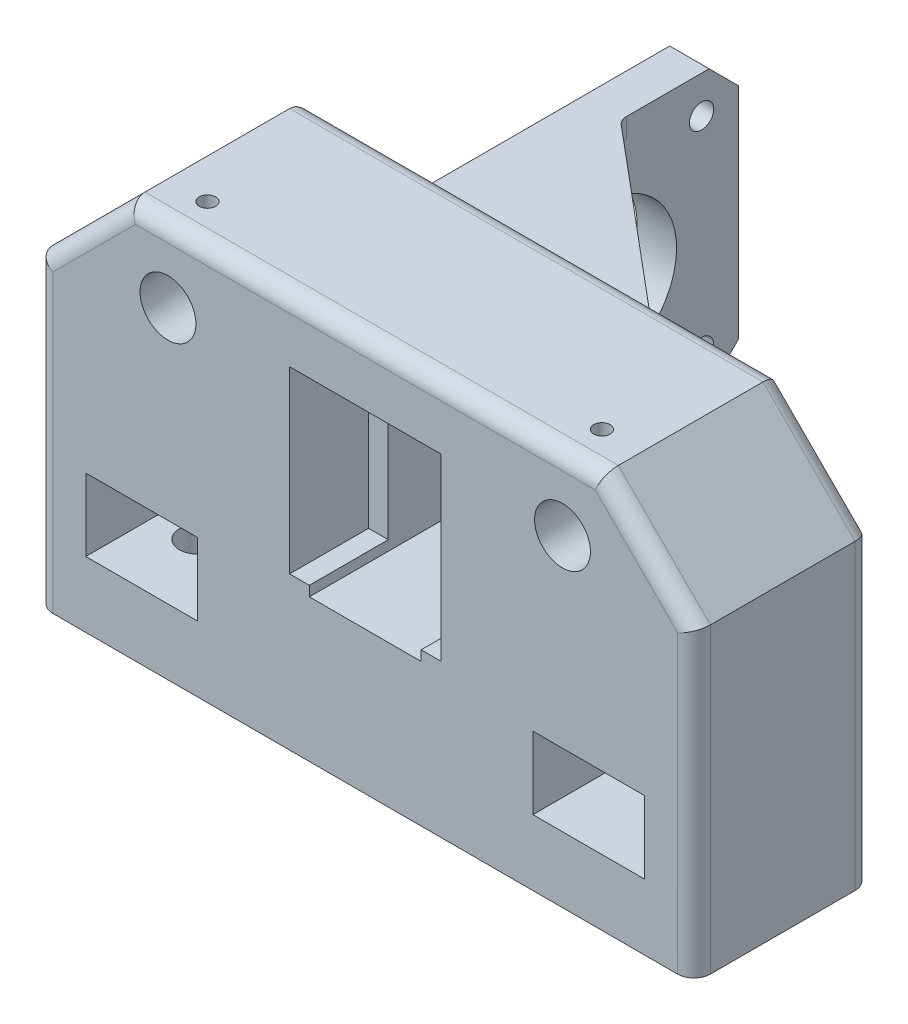
from build123d import *

# Parameters (mm, degrees)
SKETCH1_W            = 100
SKETCH1_H            = 60
SKETCH1_R            = 4.25
BOSS_EXTRUDE1_DEPTH  = 13.5
SKETCH2_R            = 7
BOSS_EXTRUDE2_DEPTH  = 10
CHAMFER1_SIZE        = 14
FILLET1_R            = 2.5
CUT_EXTRUDE1_DEPTH   = 12
SKETCH5_R            = 1.25
CUT_EXTRUDE2_DEPTH   = 12
SKETCH6_R            = 2.75
CUT_EXTRUDE3_DEPTH   = 10
CUT_EXTRUDE4_DEPTH   = 17
SKETCH11_W           = 17
SKETCH11_H           = 28.01
CUT_EXTRUDE5_DEPTH   = 28.0000001
SKETCH13_R           = 4.25
BOSS_EXTRUDE6_DEPTH  = 9
SKETCH14_R           = 1.85
SKETCH14_R_2         = 11.7
BOSS_EXTRUDE7_DEPTH  = 6
BOSS_EXTRUDE8_START  = 4
BOSS_EXTRUDE8_DEPTH  = 3
SKETCH17_W           = 6
SKETCH17_H           = 42.718705864
BOSS_EXTRUDE9_DEPTH  = 1
BOSS_EXTRUDE12_DEPTH = 3
SKETCH19_W           = 6
SKETCH19_H           = 24.5
BOSS_EXTRUDE13_DEPTH = 6
SKETCH21_W           = 6
SKETCH21_H           = 21.281155669
BOSS_EXTRUDE14_DEPTH = 3
BOSS_EXTRUDE15_DEPTH = 3
FILLET3_R            = 2


with BuildPart() as part:
    # Sketch1 → Boss-Extrude1 (new body, symmetric)
    with BuildSketch(Plane.XY):
        with Locations((0, -19)):
            Rectangle(SKETCH1_W, SKETCH1_H)
        with Locations((30, 0)):
            Circle(SKETCH1_R, mode=Mode.SUBTRACT)
        with Locations((-30, 0)):
            Circle(SKETCH1_R, mode=Mode.SUBTRACT)
    extrude(amount=BOSS_EXTRUDE1_DEPTH, both=True)

    # Sketch2 → Boss-Extrude2 (add)
    with BuildSketch(Plane(origin=(0, 0, -13.5), x_dir=(-1, 0, 0), z_dir=(0, 0, -1))):
        with Locations((-30, 0)):
            Circle(SKETCH2_R)
        with Locations((30, 0)):
            Circle(SKETCH2_R)
    extrude(amount=-BOSS_EXTRUDE2_DEPTH)

    # Chamfer1
    chamfer1_edges = [part.edges().sort_by_distance(p)[0] for p in [
        (-50, 11, 0),
        (50, 11, 0),
    ]]
    chamfer(chamfer1_edges, length=CHAMFER1_SIZE)

    # Fillet1
    fillet1_edges = [part.edges().sort_by_distance(p)[0] for p in [
        (-50, -26, -13.5),
        (-50, -26, 13.5),
        (0, 11, -13.5),
        (43, 4, -13.5),
        (-43, 4, -13.5),
        (0, 11, 13.5),
        (50, -26, 13.5),
        (43, 4, 13.5),
        (-43, 4, 13.5),
        (50, -26, -13.5),
    ]]
    fillet(fillet1_edges, radius=FILLET1_R)

    # Sketch3 → Cut-Extrude1 (cut)
    with BuildSketch(Plane.XY.offset(13.5)):
        Polygon((11.5, 1.5), (-11.5, 1.5), (-11.5, -14.75), (-11.5, -25.79), (11.5, -25.79), (11.5, -14.75), align=None)
    extrude(amount=-CUT_EXTRUDE1_DEPTH, mode=Mode.SUBTRACT)

    # Sketch5 → Cut-Extrude2 (cut)
    with BuildSketch(Plane(origin=(0, 11, 0), x_dir=(1, 0, 0), z_dir=(0, 1, 0))):
        with Locations((30, -7.5)):
            Circle(SKETCH5_R)
        with Locations((-30, -7.5)):
            Circle(SKETCH5_R)
    extrude(amount=-CUT_EXTRUDE2_DEPTH, mode=Mode.SUBTRACT)

    # Sketch6 → Cut-Extrude3 (cut)
    with BuildSketch(Plane.XZ.offset(49)):
        with Locations((36.277796695, 2.75)):
            Circle(SKETCH6_R)
    cut_extrude3 = extrude(amount=-CUT_EXTRUDE3_DEPTH, mode=Mode.SUBTRACT)

    # Sketch7 → Cut-Extrude4 (cut)
    with BuildSketch(Plane.XY.offset(13.5)):
        Polygon((42.5, -39), (30.5, -39), (25.5, -39), (25.5, -28), (30.5, -28), (42.5, -28), align=None)
    cut_extrude4 = extrude(amount=-CUT_EXTRUDE4_DEPTH, mode=Mode.SUBTRACT)

    # Mirror1: Cut-Extrude3, Cut-Extrude4 across plane
    add(cut_extrude3.mirror(Plane(origin=(0, 0, 0), x_dir=(0, 0, 1), z_dir=(1, 0, 0))), mode=Mode.SUBTRACT)
    add(cut_extrude4.mirror(Plane(origin=(0, 0, 0), x_dir=(0, 0, 1), z_dir=(1, 0, 0))), mode=Mode.SUBTRACT)

    # Sketch11 → Cut-Extrude5 (cut, through all)
    with BuildSketch(Plane(origin=(0, 0, -13.5), x_dir=(-1, 0, 0), z_dir=(0, 0, -1))):
        with Locations((0, -13.310174912)):
            Rectangle(SKETCH11_W, SKETCH11_H)
    extrude(amount=-CUT_EXTRUDE5_DEPTH, mode=Mode.SUBTRACT)

    # Sketch13 → Boss-Extrude6 (add)
    with BuildSketch(Plane.XY.offset(-3.5)):
        with Locations((30, 0)):
            Circle(SKETCH13_R)
        with Locations((-30, 0)):
            Circle(SKETCH13_R)
    extrude(amount=BOSS_EXTRUDE6_DEPTH)

    # Sketch14 → Boss-Extrude7 (add)
    with BuildSketch(Plane(origin=(-18.5, 0, 0), x_dir=(0, 0, -1), z_dir=(1, 0, 0))):
        Polygon((55.8, -29.960174912), (55.8, 3.339825088), (51.3, 7.839825088), (18, 7.839825088), (11, 7.839825088), (11, -34.460174912), (18, -34.460174912), (51.3, -34.460174912), align=None)
        with Locations((50.15, -28.810174912)):
            Circle(SKETCH14_R, mode=Mode.SUBTRACT)
        with Locations((50.15, 2.189825088)):
            Circle(SKETCH14_R, mode=Mode.SUBTRACT)
        with Locations((19.15, 2.189825088)):
            Circle(SKETCH14_R, mode=Mode.SUBTRACT)
        with Locations((19.15, -28.810174912)):
            Circle(SKETCH14_R, mode=Mode.SUBTRACT)
        with Locations((34.65, -13.310174912)):
            Circle(SKETCH14_R_2, mode=Mode.SUBTRACT)
    extrude(amount=BOSS_EXTRUDE7_DEPTH)

    # Sketch15 → Boss-Extrude8 (add)
    with BuildSketch(Plane.XZ.offset(34.460174912).offset(BOSS_EXTRUDE8_START)):
        Polygon((-14.5, -39.5), (20.060854185, -10.5), (-14.5, -10.5), align=None)
    extrude(amount=-BOSS_EXTRUDE8_DEPTH)

    # Sketch17 → Boss-Extrude9 (add)
    with BuildSketch(Plane.XZ.offset(34.460174912)):
        with Locations((-15.5, -29.940647068)):
            Rectangle(SKETCH17_W, SKETCH17_H)
    extrude(amount=BOSS_EXTRUDE9_DEPTH)

    # Sketch18 → Boss-Extrude12 (add)
    with BuildSketch(Plane.XZ.offset(35.460174912)):
        Polygon((-18.5, -10.5), (-41.575239857, -10.5), (-18.5, -38), (-13.739171521, -38), (-13.739171521, -10.5), align=None)
    extrude(amount=BOSS_EXTRUDE12_DEPTH)

    # Sketch19 → Boss-Extrude13 (add)
    with BuildSketch(Plane.XZ.offset(38.460174912)):
        with Locations((-15.5, -25.75)):
            Rectangle(SKETCH19_W, SKETCH19_H)
    extrude(amount=-BOSS_EXTRUDE13_DEPTH)

    # Sketch21 → Boss-Extrude14 (add)
    with BuildSketch(Plane.XZ.offset(35.460174912)):
        with Locations((-15.5, -40.659422166)):
            Rectangle(SKETCH21_W, SKETCH21_H)
    extrude(amount=BOSS_EXTRUDE14_DEPTH)

    # Sketch22 → Boss-Extrude15 (add)
    with BuildSketch(Plane(origin=(0, 7.839825088, 0), x_dir=(1, 0, 0), z_dir=(0, 1, 0))):
        Polygon((-12.5, 37.821800738), (-15.5, 37.821800738), (-15.5, 11), (-12.5, 11), (16.485593407, 11), (16.485593407, 13.5), align=None)
    extrude(amount=-BOSS_EXTRUDE15_DEPTH)

    # Fillet3
    fillet3_edges = [part.edges().sort_by_distance(p)[0] for p in [
        (-12.5, 6.339825088, -37.821800738),
        (-39.057940964, -36.960174912, -13.5),
        (-18.5, -36.960174912, -38),
        (16.485593407, 6.339825088, -13.5),
        (16.485593407, -36.960174912, -13.5),
        (-12.5, -36.960174912, -37.821800738),
        (-11.286173778, -38.460174912, -13.5),
        (-12.5, -35.460174912, -25.660900369),
        (1.992796704, -35.460174912, -13.5),
        (-12.5, -15.310174912, -13.5),
        (1.992796704, 4.839825088, -13.5),
    ]]
    fillet(fillet3_edges, radius=FILLET3_R)


solid = part.part
